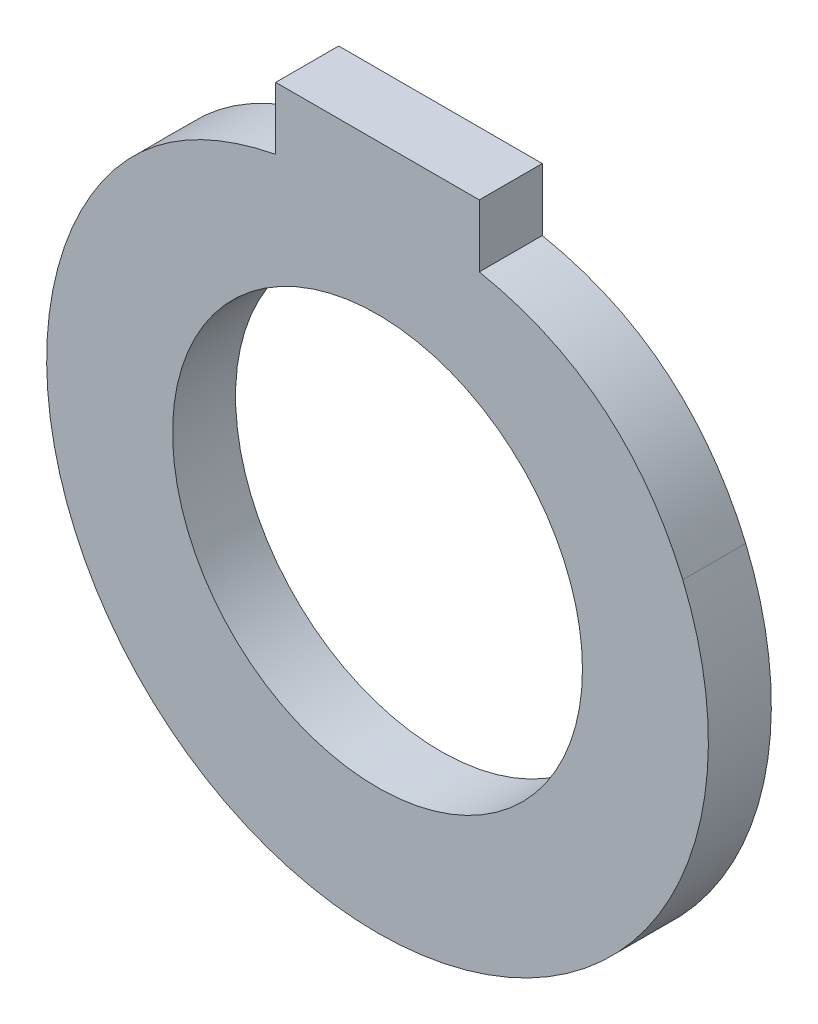
from build123d import *

# Parameters (mm, degrees)
SKETCH1_R           = 20.66925
BOSS_EXTRUDE1_DEPTH = 6.35


with BuildPart() as part:
    # Sketch1 → Boss-Extrude1 (new body)
    with BuildSketch(Plane.XY):
        with BuildLine():
            Line((-10.265793628, 35.791116693), (10.265793628, 35.791116693))
            Line((10.265793628, 35.791116693), (10.265793628, 29.50036983))
            add(Edge.make_bspline(
                [(30.787817782, 12.869231593), (24.871862383, 26.630631307), (10.265793628, 29.50036983)],
                knots=[0, 0, 0, 1, 1, 1], degree=2))
            ThreePointArc((30.787817782, 12.869231593), (0, -33.36925), (-30.787817782, 12.869231593))
            add(Edge.make_bspline(
                [(-30.787817782, 12.869231593), (-24.871862383, 26.630631307), (-10.265793628, 29.50036983)],
                knots=[0, 0, 0, 1, 1, 1], degree=2))
            Line((-10.265793628, 29.50036983), (-10.265793628, 35.791116693))
        make_face()
        Circle(SKETCH1_R, mode=Mode.SUBTRACT)
    extrude(amount=BOSS_EXTRUDE1_DEPTH)


solid = part.part
